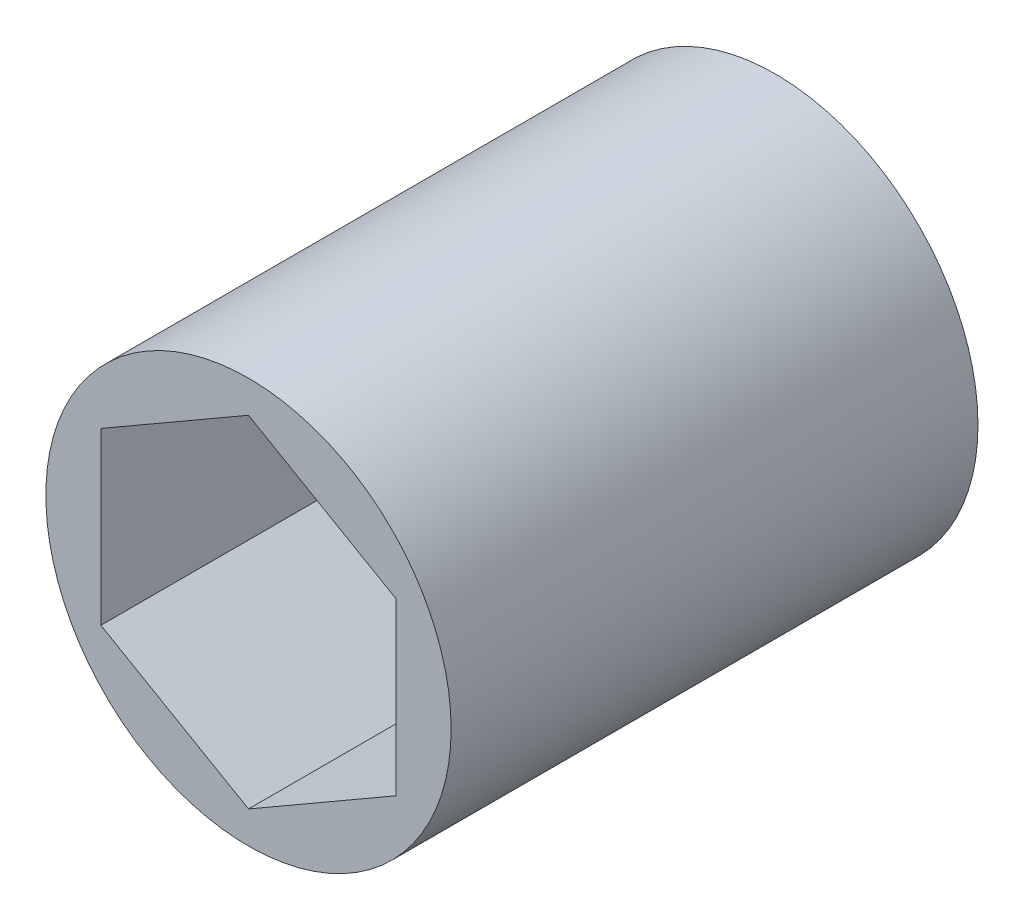
from build123d import *

# Parameters (mm, degrees)
SKETCH1_R           = 8.89
BOSS_EXTRUDE1_DEPTH = 23.114


with BuildPart() as part:
    # Sketch1 → Boss-Extrude1 (new body)
    with BuildSketch(Plane.XY):
        Circle(SKETCH1_R)
        Polygon((0, 7.478995387), (-6.477, 3.739497694), (-6.477, -3.739497694), (0, -7.478995387), (6.477, -3.739497694), (6.477, 3.739497694), align=None, mode=Mode.SUBTRACT)
    extrude(amount=BOSS_EXTRUDE1_DEPTH)


solid = part.part
